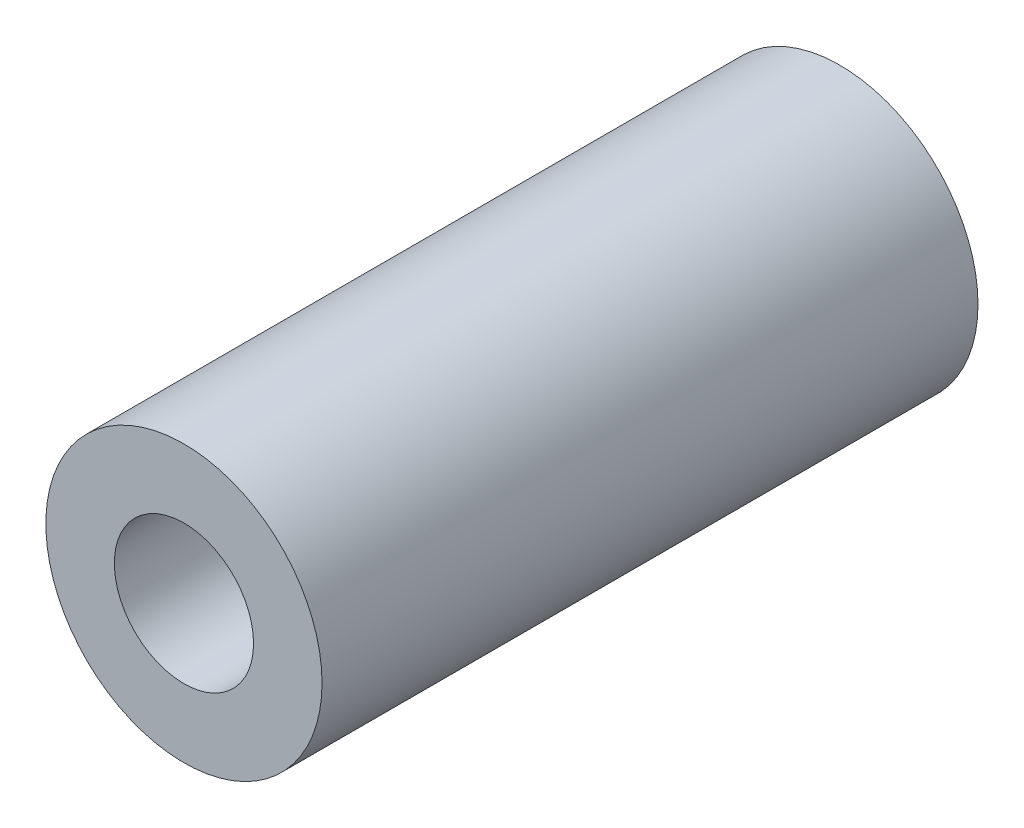
from build123d import *

# Parameters (mm, degrees)
SKETCH1_R      = 6.35
SKETCH1_R_2    = 3.2004
EXTRUDE1_DEPTH = 15.08125


with BuildPart() as part:
    # Sketch1 → Extrude1 (new body, symmetric)
    with BuildSketch(Plane.XY):
        Circle(SKETCH1_R)
        Circle(SKETCH1_R_2, mode=Mode.SUBTRACT)
    extrude(amount=EXTRUDE1_DEPTH, both=True)


solid = part.part
